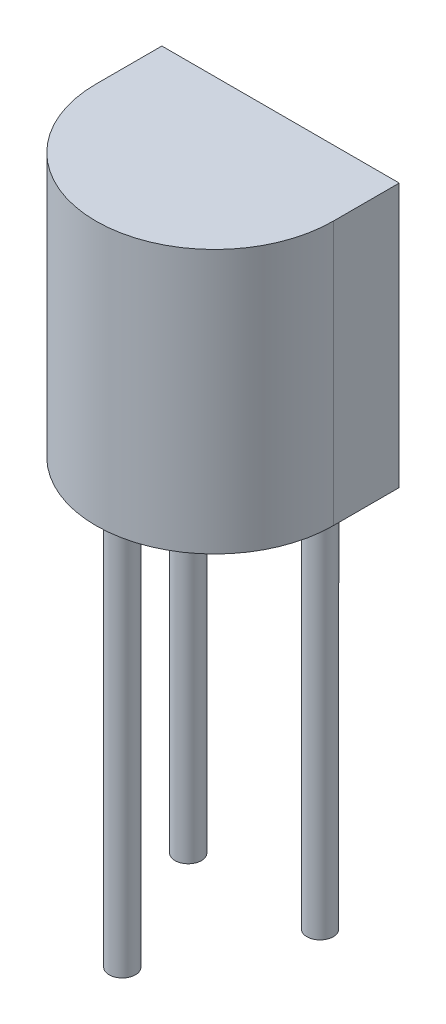
from build123d import *

# Parameters (mm, degrees)
BOSS_EXTRUDE1_DEPTH = 5
SKETCH2_R           = 0.25
BOSS_EXTRUDE2_DEPTH = 7.5


with BuildPart() as part:
    # Sketch1 → Boss-Extrude1 (new body)
    with BuildSketch(Plane(origin=(0, 0, 0), x_dir=(1, 0, 0), z_dir=(0, 1, 0))):
        with BuildLine():
            Line((0, 1.25), (4.5, 1.25))
            Line((4.5, 1.25), (4.5, 0))
            ThreePointArc((4.5, 0), (2.25, -2.25), (0, 0))
            Line((0, 0), (0, 1.25))
        make_face()
    extrude(amount=BOSS_EXTRUDE1_DEPTH)

    # Sketch2 → Boss-Extrude2 (add)
    with BuildSketch(Plane.XZ):
        with Locations((1, -0.75)):
            Circle(SKETCH2_R)
        with Locations((3.5, -0.75)):
            Circle(SKETCH2_R)
        with Locations((2.25, 1.75)):
            Circle(SKETCH2_R)
    extrude(amount=BOSS_EXTRUDE2_DEPTH)


solid = part.part
